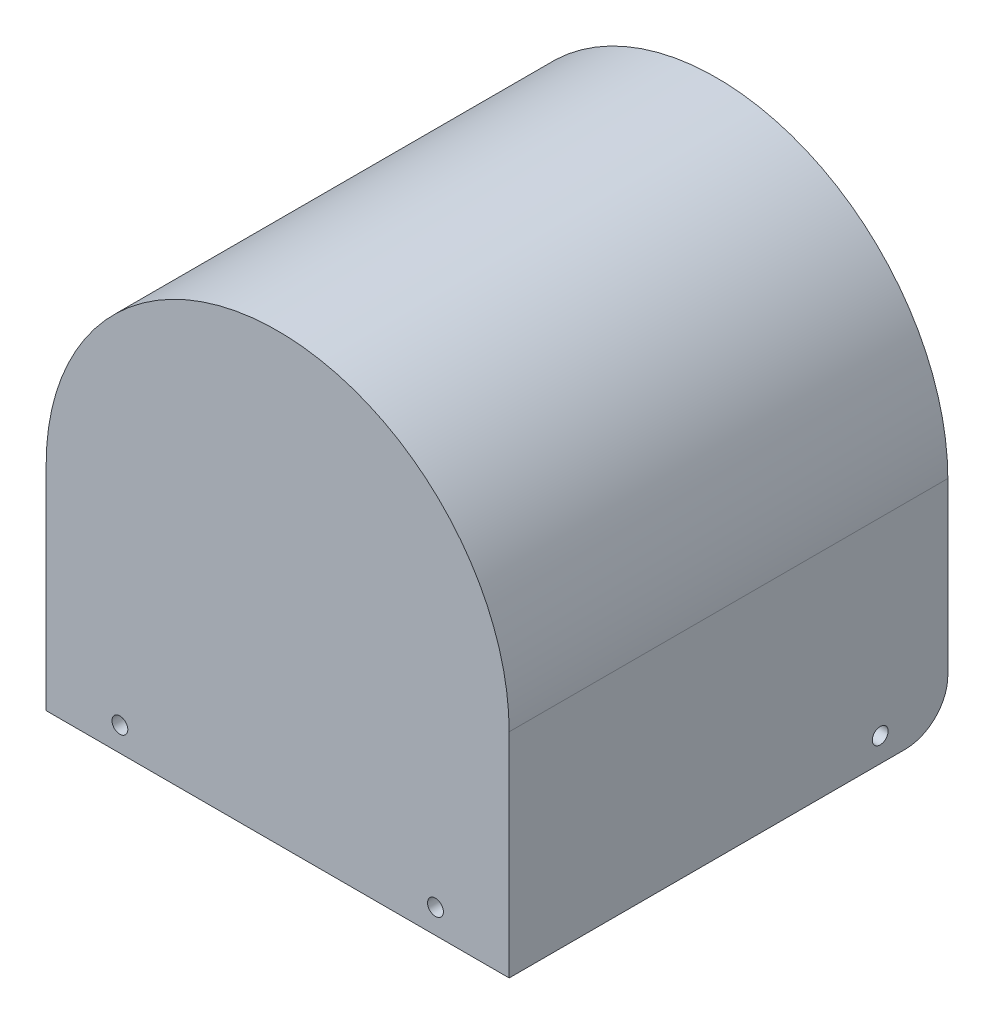
from build123d import *

# Parameters (mm, degrees)
BOSS_EXTRUDE1_DEPTH                  = 72
SKETCH2_W                            = 72
SKETCH2_H                            = 2
BOSS_EXTRUDE2_DEPTH                  = 35
BOSS_EXTRUDE2_DIRECTION_2_REACH      = 91.844
BOSS_EXTRUDE2_DIRECTION_2_END_RADIUS = 36
SKETCH3_R                            = 1.3
CUT_EXTRUDE1_DEPTH                   = 10
SKETCH4_R                            = 1.3
CUT_EXTRUDE2_DEPTH                   = 112.373246339
FILLET1_R                            = 7


with BuildPart() as part:
    # Sketch1 → Boss-Extrude1 (new body)
    with BuildSketch(Plane.XY):
        with BuildLine():
            Line((-36, 0), (-36, -35))
            Line((-36, -35), (-38, -35))
            Line((-38, -35), (-38, 0))
            ThreePointArc((-38, 0), (0, 38), (38, 0))
            Line((38, 0), (38, -35))
            Line((38, -35), (36, -35))
            Line((36, -35), (36, 0))
            ThreePointArc((36, 0), (0, 36), (-36, 0))
        make_face()
    extrude(amount=BOSS_EXTRUDE1_DEPTH)

    # Sketch2 → Boss-Extrude2 (add)
    with BuildSketch(Plane(origin=(0, 0, 0), x_dir=(1, 0, 0), z_dir=(0, 1, 0))):
        with Locations((0, -71)):
            Rectangle(SKETCH2_W, SKETCH2_H)
    extrude(amount=-BOSS_EXTRUDE2_DEPTH)

    # Boss-Extrude2 direction 2: up to this cylinder (the profile starts inside it)
    boss_extrude2_direction_2_end = Plane(origin=(0, 0, 71), z_dir=(0, 0, -1)) * Cylinder(BOSS_EXTRUDE2_DIRECTION_2_END_RADIUS, 256.688, mode=Mode.PRIVATE)
    # Sketch2 → Boss-Extrude2 direction 2 (add, up to the surface)
    with BuildSketch(Plane(origin=(0, 0, 0), x_dir=(1, 0, 0), z_dir=(0, 1, 0)), mode=Mode.PRIVATE) as boss_extrude2_direction_2_sk1:
        with Locations((0, -71)):
            Rectangle(SKETCH2_W, SKETCH2_H)
    boss_extrude2_direction_2_tool1 = extrude(boss_extrude2_direction_2_sk1.sketch, amount=BOSS_EXTRUDE2_DIRECTION_2_REACH, mode=Mode.PRIVATE) & boss_extrude2_direction_2_end
    add(boss_extrude2_direction_2_tool1.solids().sort_by_distance((0, 0, 71))[0])

    # Sketch3 → Cut-Extrude1 (cut)
    with BuildSketch(Plane.XY.offset(72)):
        with Locations((-25.9, -31)):
            Circle(SKETCH3_R)
        with Locations((25.9, -31)):
            Circle(SKETCH3_R)
    extrude(amount=-CUT_EXTRUDE1_DEPTH, mode=Mode.SUBTRACT)

    # Sketch4 → Cut-Extrude2 (cut, through all)
    with BuildSketch(Plane(origin=(38, 0, 0), x_dir=(0, 0, -1), z_dir=(1, 0, 0))):
        with Locations(Location((-11.1, -31, 0), (0, 0, 90))):
            Circle(SKETCH4_R)
    extrude(amount=-CUT_EXTRUDE2_DEPTH, mode=Mode.SUBTRACT)

    # Fillet1
    fillet1_edges = [part.edges().sort_by_distance(p)[0] for p in [
        (-37, -35, 0),
        (37, -35, 0),
    ]]
    fillet(fillet1_edges, radius=FILLET1_R)


solid = part.part
